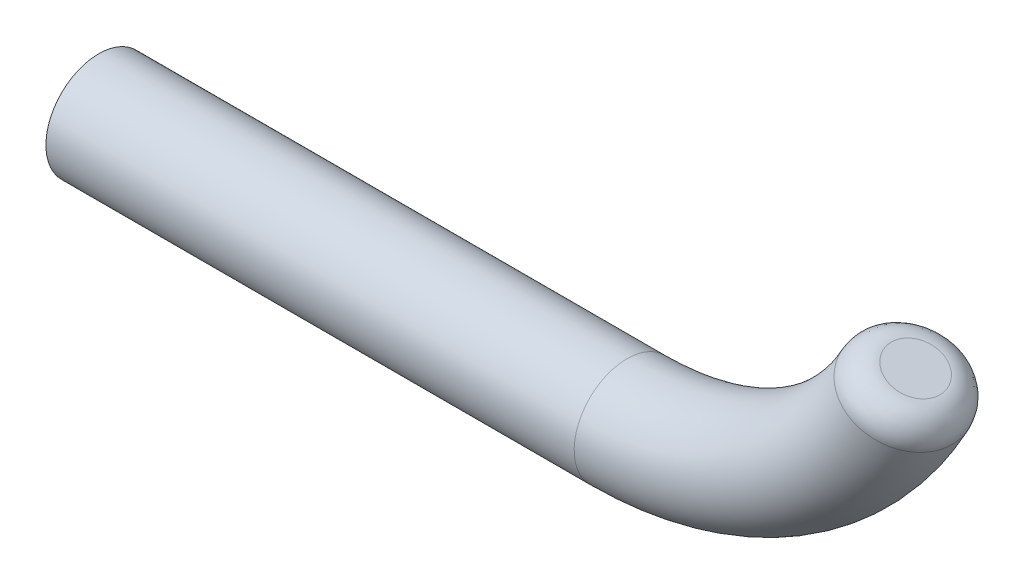
from build123d import *

# Parameters (mm, degrees)
SKETCH2_R = 5
FILLET1_R = 2.5


with BuildPart() as part:
    # Sweep1: sweep along a path in Sketch1
    with BuildLine(Plane.XY) as sweep1_path:
        Line((0, -5), (50, -5))
        ThreePointArc((50, -5), (66.347406225, -0.154767137), (77.414346459, 12.815846018))
    # Sketch2 → Sweep1 (sweep)
    with BuildSketch(Plane(origin=(0, 0, 0), x_dir=(0, 0, -1), z_dir=(1, 0, 0))):
        with Locations((0, -5)):
            Circle(SKETCH2_R)
    sweep(path=sweep1_path.line)

    # Fillet1
    fillet1_edges = [part.edges().sort_by_distance(p)[0] for p in [
        (77.414346459, 12.815846018, 5),
    ]]
    fillet(fillet1_edges, radius=FILLET1_R)


solid = part.part
